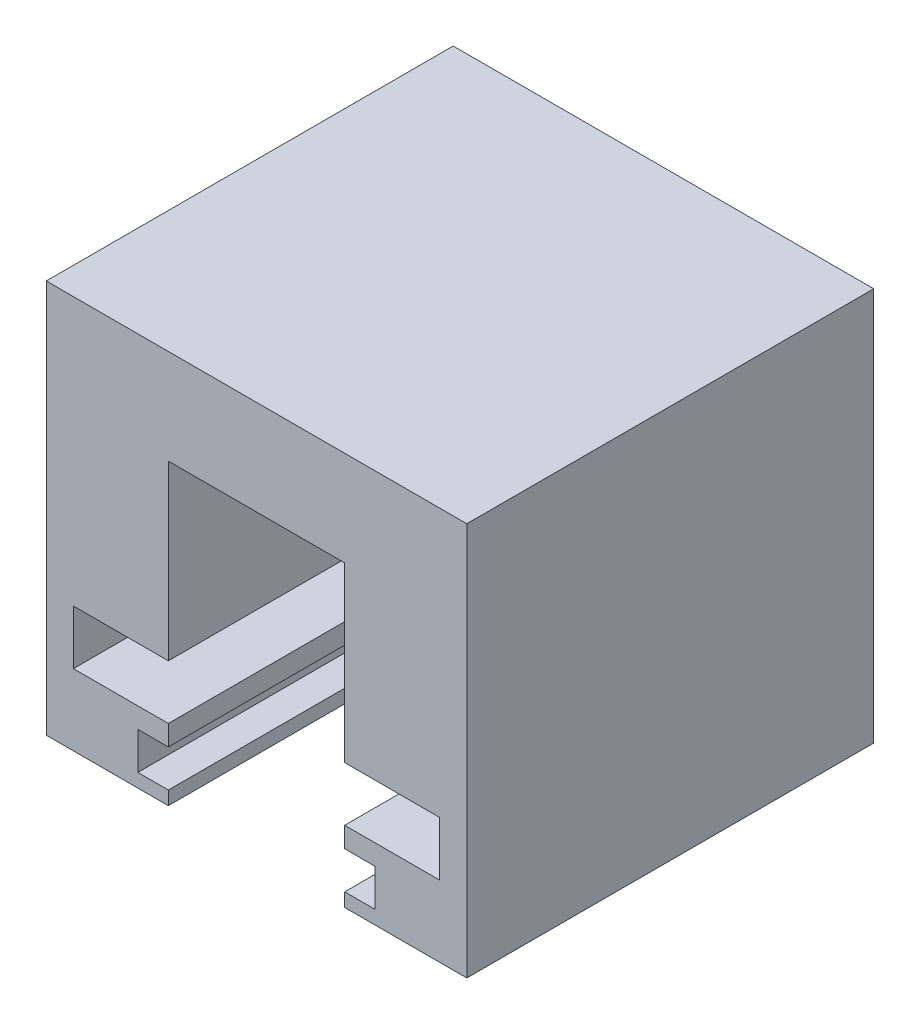
from build123d import *

# Parameters (mm, degrees)
BOSS_EXTRUDE2_DEPTH = 30


with BuildPart() as part:
    # Sketch1 → Boss-Extrude2 (new body)
    with BuildSketch(Plane.XY):
        Polygon((-31, 29), (-31, 0), (-22, 0), (-22, 1), (-24.25, 1), (-24.25, 3.75), (-22, 3.75), (-22, 5.25), (-29, 5.25), (-29, 9.25), (-22, 9.25), (-22, 22), (-9, 22), (-9, 9.25), (-2, 9.25), (-2, 5.25), (-9, 5.25), (-9, 3.75), (-6.75, 3.75), (-6.75, 1), (-9, 1), (-9, 0), (0, 0), (0, 29), align=None)
    extrude(amount=BOSS_EXTRUDE2_DEPTH)


solid = part.part
